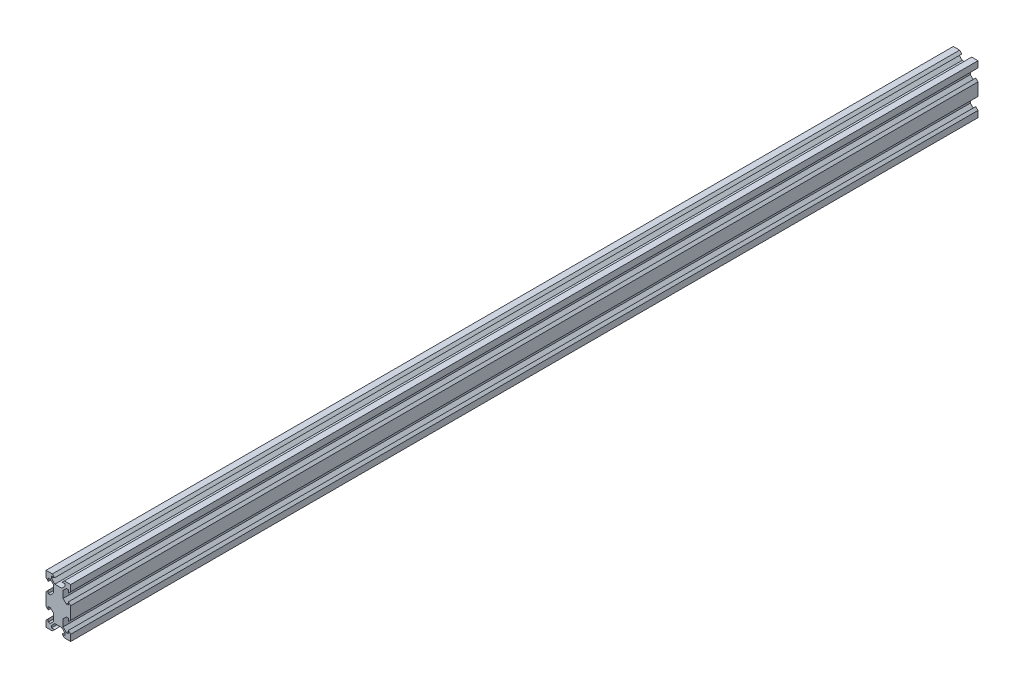
from build123d import *

# Parameters (mm, degrees)
SKETCH1_W           = 20
SKETCH1_H           = 40
BOSS_EXTRUDE1_DEPTH = 735.0125
CUT_EXTRUDE1_DEPTH  = 736.0125


with BuildPart() as part:
    # Sketch1 → Boss-Extrude1 (new body)
    with BuildSketch(Plane.XY):
        with Locations((10, 20)):
            Rectangle(SKETCH1_W, SKETCH1_H)
    extrude(amount=BOSS_EXTRUDE1_DEPTH)

    # Sketch2 → Cut-Extrude1 (cut, through all)
    with BuildSketch(Plane.XY.offset(735.0125)):
        Polygon((5.12, 40), (6.94, 38.18), (4.5, 38.18), (4.5, 36.475807358), (7.165807358, 33.81), (12.834192642, 33.81), (15.5, 36.475807358), (15.5, 38.18), (13.06, 38.18), (14.88, 40), align=None)
        Polygon((18.18, 35.5), (18.18, 33.06), (20, 34.88), (20, 25.12), (18.18, 26.94), (18.18, 24.5), (16.475807358, 24.5), (13.81, 27.165807358), (13.81, 32.834192642), (16.475807358, 35.5), align=None)
        Polygon((20, 14.88), (18.18, 13.06), (18.18, 15.5), (16.475807358, 15.5), (13.81, 12.834192642), (13.81, 7.165807358), (16.475807358, 4.5), (18.18, 4.5), (18.18, 6.94), (20, 5.12), align=None)
        Polygon((15.5, 1.82), (13.06, 1.82), (14.88, 0), (5.12, 0), (6.94, 1.82), (4.5, 1.82), (4.5, 3.524192642), (7.165807358, 6.19), (12.834192642, 6.19), (15.5, 3.524192642), align=None)
        Polygon((1.82, 4.5), (1.82, 6.94), (0, 5.12), (0, 14.88), (1.82, 13.06), (1.82, 15.5), (3.524192642, 15.5), (6.19, 12.834192642), (6.19, 7.165807358), (3.524192642, 4.5), align=None)
        Polygon((0, 25.12), (1.82, 26.94), (1.82, 24.5), (3.524192642, 24.5), (6.19, 27.165807358), (6.19, 32.834192642), (3.524192642, 35.5), (1.82, 35.5), (1.82, 33.06), (0, 34.88), align=None)
    extrude(amount=-CUT_EXTRUDE1_DEPTH, mode=Mode.SUBTRACT)


solid = part.part
